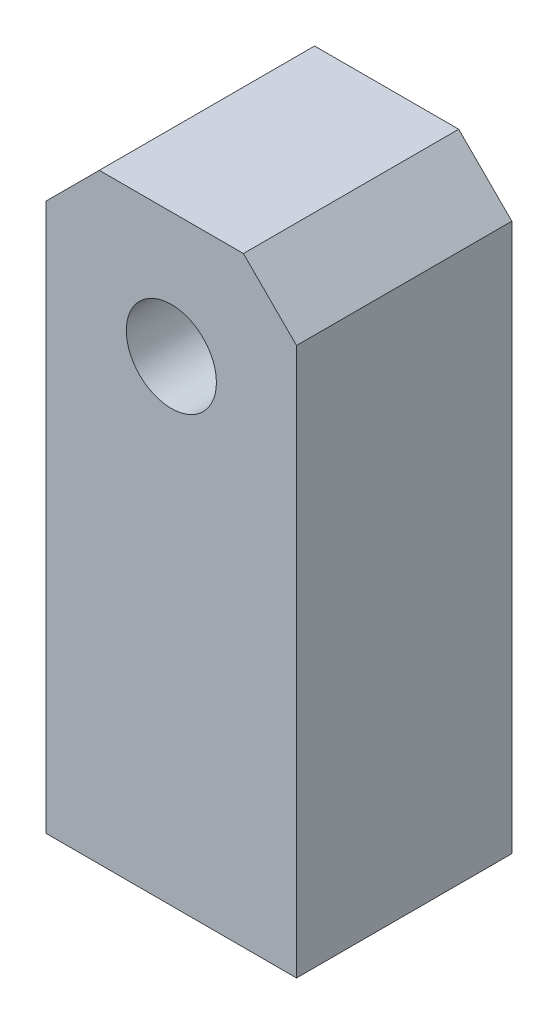
from build123d import *

# Parameters (mm, degrees)
SKETCH1_R           = 0.9
BOSS_EXTRUDE1_DEPTH = 4.3


with BuildPart() as part:
    # Sketch1 → Boss-Extrude1 (new body)
    with BuildSketch(Plane.XY):
        Polygon((2.5, 1.439339828), (1.439339828, 2.5), (-1.439339828, 2.5), (-2.5, 1.439339828), (-2.5, -9.5), (2.5, -9.5), align=None)
        Circle(SKETCH1_R, mode=Mode.SUBTRACT)
    extrude(amount=BOSS_EXTRUDE1_DEPTH)


solid = part.part
